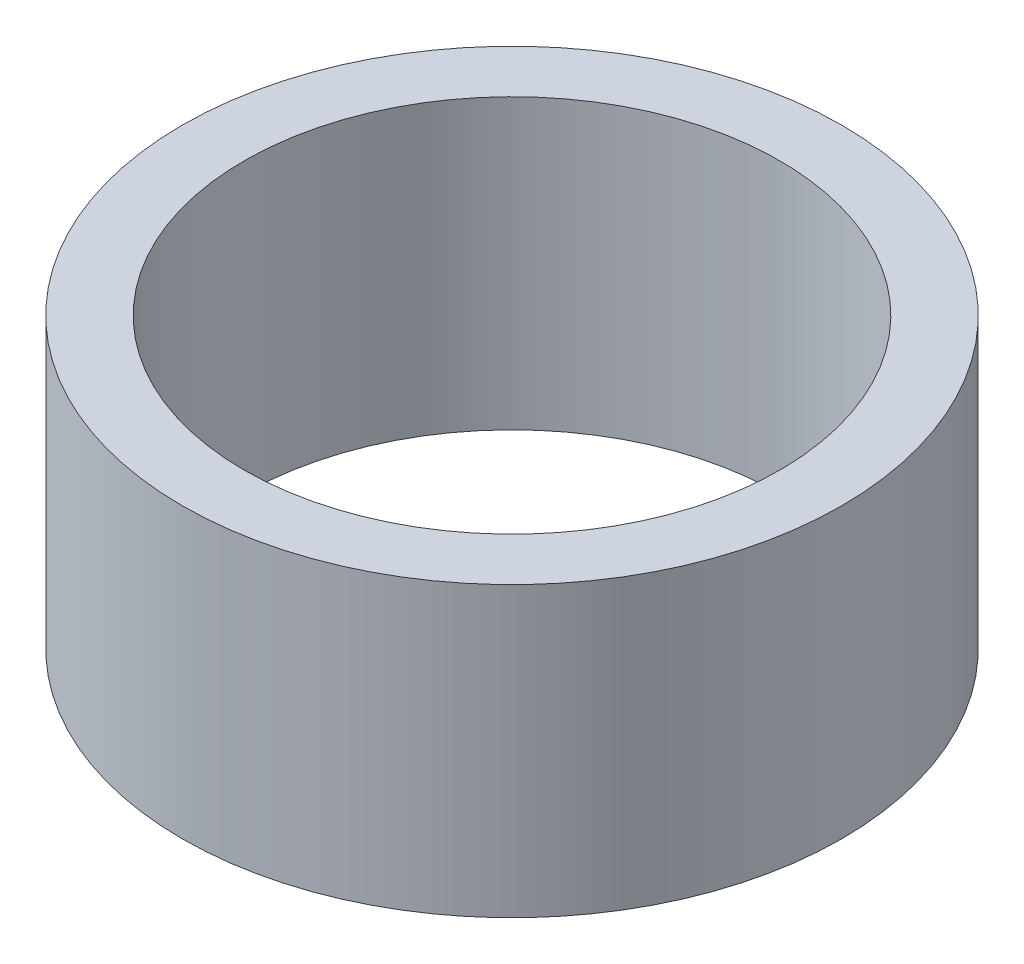
from build123d import *

# Parameters (mm, degrees)
SKETCH1_R           = 16
SKETCH1_R_2         = 13
EXTRUDE_THIN1_DEPTH = 14


with BuildPart() as part:
    # Sketch1 → Extrude-Thin1 (new body)
    with BuildSketch(Plane(origin=(0, 0, 0), x_dir=(1, 0, 0), z_dir=(0, 1, 0))):
        Circle(SKETCH1_R)
        Circle(SKETCH1_R_2, mode=Mode.SUBTRACT)
    extrude(amount=EXTRUDE_THIN1_DEPTH)


solid = part.part
